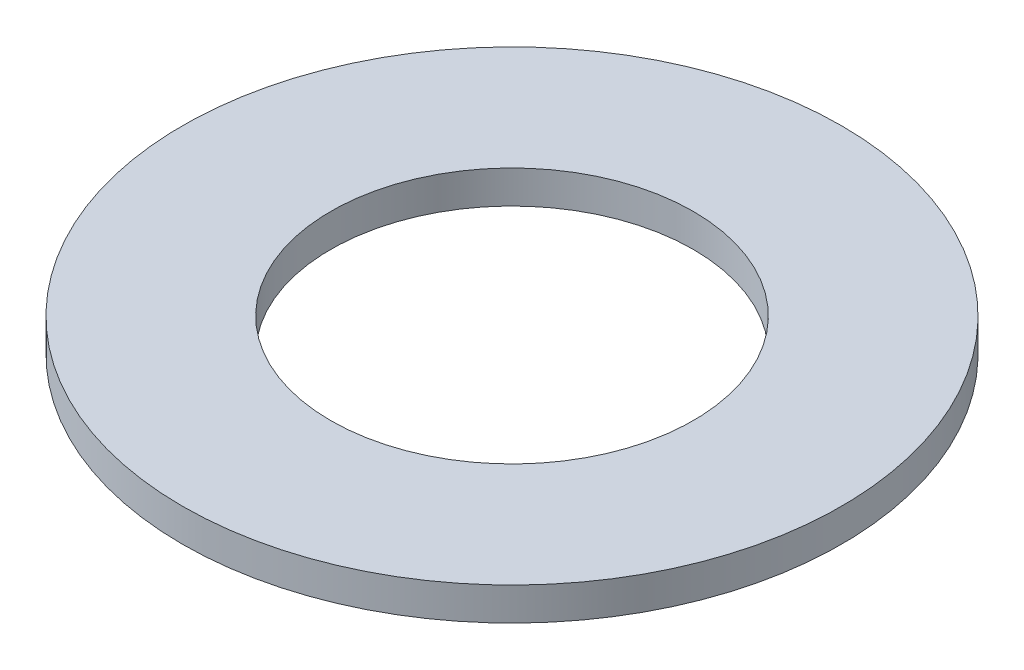
from build123d import *

# Parameters (mm, degrees)
SKETCH1_R           = 20
SKETCH1_R_2         = 11
BOSS_EXTRUDE1_DEPTH = 2


with BuildPart() as part:
    # Sketch1 → Boss-Extrude1 (new body)
    with BuildSketch(Plane(origin=(0, 0, 0), x_dir=(1, 0, 0), z_dir=(0, 1, 0))):
        Circle(SKETCH1_R)
        Circle(SKETCH1_R_2, mode=Mode.SUBTRACT)
    extrude(amount=BOSS_EXTRUDE1_DEPTH)


solid = part.part
